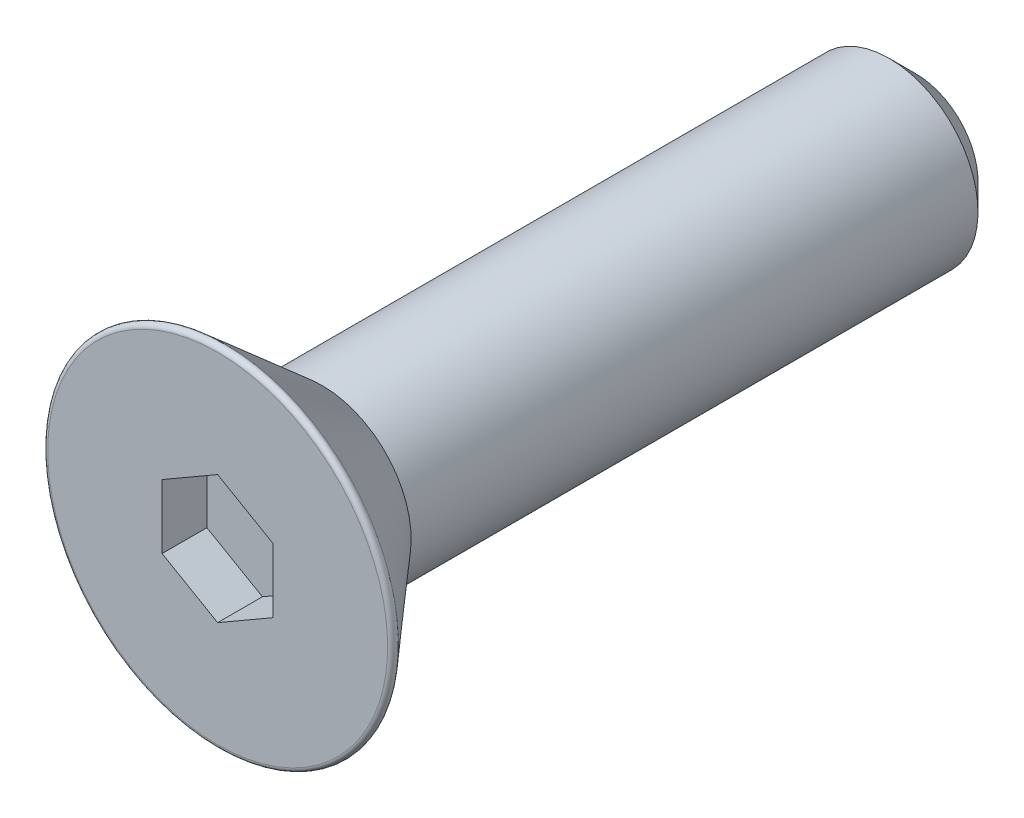
from build123d import *

# Parameters (mm, degrees)
SKETCH10_R         = 2.291358881
CUT_EXTRUDE2_DEPTH = 2.0447
CUT_EXTRUDE2_DRAFT = -45
CUT_EXTRUDE1_DEPTH = 2.0447


with BuildPart() as part:
    # Sketch2 → Revolve1 (revolve)
    with BuildSketch(Plane(origin=(0, 0, 0), x_dir=(0, 0, -1), z_dir=(1, 0, 0))):
        Polygon((-12.618212, 6.7437), (-8.512892265, 3.175), (11.7475, 3.175), (12.7, 2.2225), (12.7, 0), (-12.7, 0), (-12.7, 6.7437), align=None)
    revolve(axis=Axis((0, 0, -12.7), (0, 0, 1)))


with BuildPart() as cut_extrude2_tool:
    # Sketch10 → Cut-Extrude2 (with draft: the straight prism first)
    with BuildSketch(Plane.XY.offset(12.7)):
        Circle(SKETCH10_R)
    extrude(amount=-CUT_EXTRUDE2_DEPTH)
    # Cut-Extrude2: the draft: its side faces are tilted about the plane it starts from
    cut_extrude2_sides = [cut_extrude2_tool.faces().sort_by_distance(p)[0] for p in [
        (-2.291358881, 0, 11.67765),
    ]]
    draft(cut_extrude2_sides, Plane.XY.offset(12.7), CUT_EXTRUDE2_DRAFT)


with BuildPart() as part_1:
    add(part.part)

    # Cut-Extrude2: cut by cut_extrude2_tool
    add(cut_extrude2_tool.part, mode=Mode.SUBTRACT)

    # Sketch9 → Cut-Extrude1 (cut)
    with BuildSketch(Plane.XY.offset(12.7)):
        Polygon((1.984375, -1.14567944), (1.984375, 1.14567944), (0, 2.291358881), (-1.984375, 1.14567944), (-1.984375, -1.14567944), (0, -2.291358881), align=None)
    extrude(amount=-CUT_EXTRUDE1_DEPTH, mode=Mode.SUBTRACT)


with BuildPart() as body_2:
    # Split1: the piece on the far side of the plane
    add(part_1.part)
    split(bisect_by=Plane.XY.offset(8.512892265), keep=Keep.BOTTOM)


with BuildPart() as part_2:
    add(part_1.part)

    # Split1
    split(bisect_by=Plane.XY.offset(8.512892265), keep=Keep.TOP)

    add(body_2.part)  # Boss-Extrude2 merges body 2
    # Boss-Extrude2 cone 1 section (through the dimple's axis) → Boss-Extrude2 (revolve)
    with BuildSketch(Plane(origin=(0, 0, 8.512892265), x_dir=(0, -1, 0), z_dir=(1, 0, 0))):
        Polygon((0, 0), (3.175, 0), (0, 8.723240807), align=None)
    revolve(axis=Axis((0, 0, 8.512892265), (0, 0, -1)))

    # Sketch12 → Cut-Revolve1 (revolve, cut)
    with BuildSketch(Plane(origin=(0, 0, 0), x_dir=(0, 0, -1), z_dir=(1, 0, 0))):
        with BuildLine():
            Line((-12.7, 0), (-12.7, 6.814797224))
            Line((-12.7, 6.814797224), (-11.988296252, 6.196122595))
            ThreePointArc((-11.988296252, 6.196122595), (-12.161061241, 6.221172326), (-12.2555, 6.074350831))
            Line((-12.2555, 6.074350831), (-12.2555, 0))
            Line((-12.2555, 0), (-12.7, 0))
        make_face()
    revolve(axis=Axis((0, 0, 0), (0, 0, 1)), mode=Mode.SUBTRACT)


solid = part_2.part
